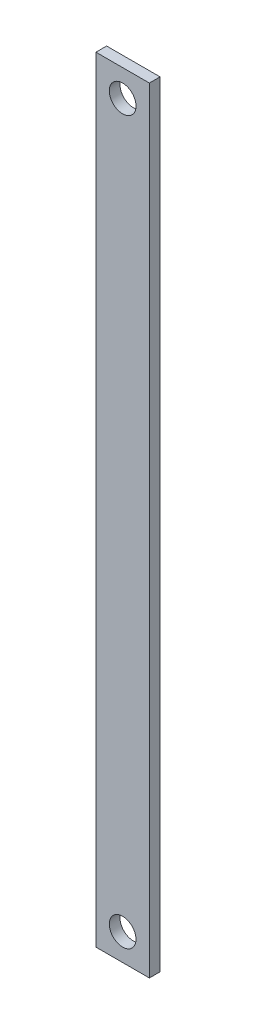
from build123d import *

# Parameters (mm, degrees)
SKETCH_1_W          = 20
SKETCH_1_H          = 4
EXTRUDE_1_DEPTH     = 290
SKETCH_2_R          = 5
CUT_EXTRUDE_1_DEPTH = 5


with BuildPart() as part:
    # Эскиз1 → Бобышка-Вытянуть1 (new body)
    with BuildSketch(Plane(origin=(0, 0, 0), x_dir=(1, 0, 0), z_dir=(0, 1, 0))):
        with Locations((10, 2)):
            Rectangle(SKETCH_1_W, SKETCH_1_H)
    extrude(amount=EXTRUDE_1_DEPTH)

    # Эскиз2 → Вырез-Вытянуть1 (cut, through all)
    with BuildSketch(Plane.XY):
        with Locations((10, 10)):
            Circle(SKETCH_2_R)
        with Locations((10, 280)):
            Circle(SKETCH_2_R)
    extrude(amount=-CUT_EXTRUDE_1_DEPTH, mode=Mode.SUBTRACT)


solid = part.part
